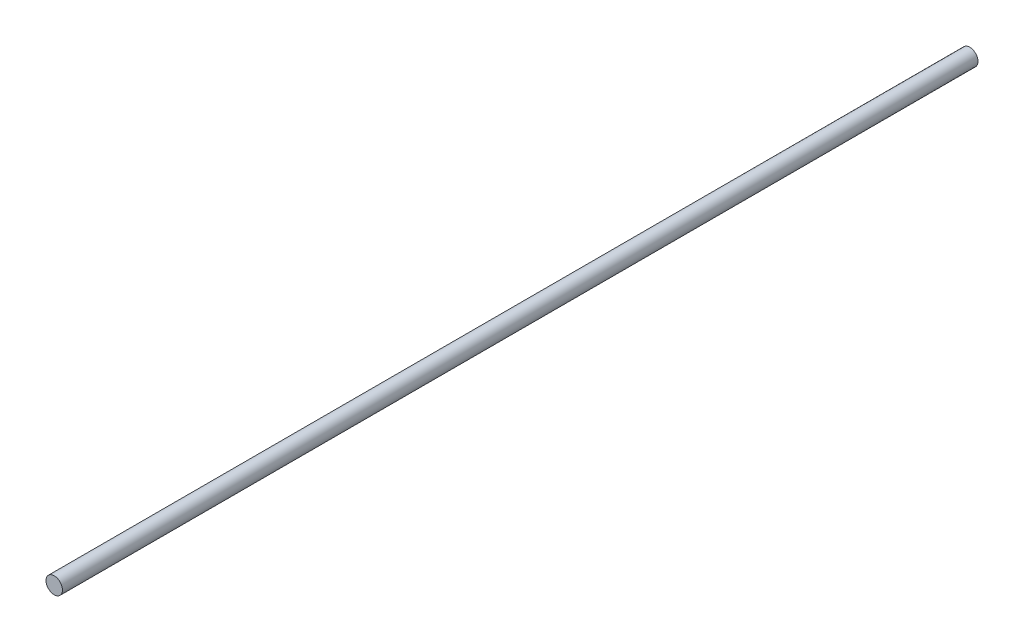
from build123d import *

# Parameters (mm, degrees)
CROQUIS1_R              = 0.9
SALIENTE_EXTRUIR1_DEPTH = 50


with BuildPart() as part:
    # Croquis1 → Saliente-Extruir1 (new body, symmetric)
    with BuildSketch(Plane.XY):
        Circle(CROQUIS1_R)
    extrude(amount=SALIENTE_EXTRUIR1_DEPTH, both=True)


solid = part.part
